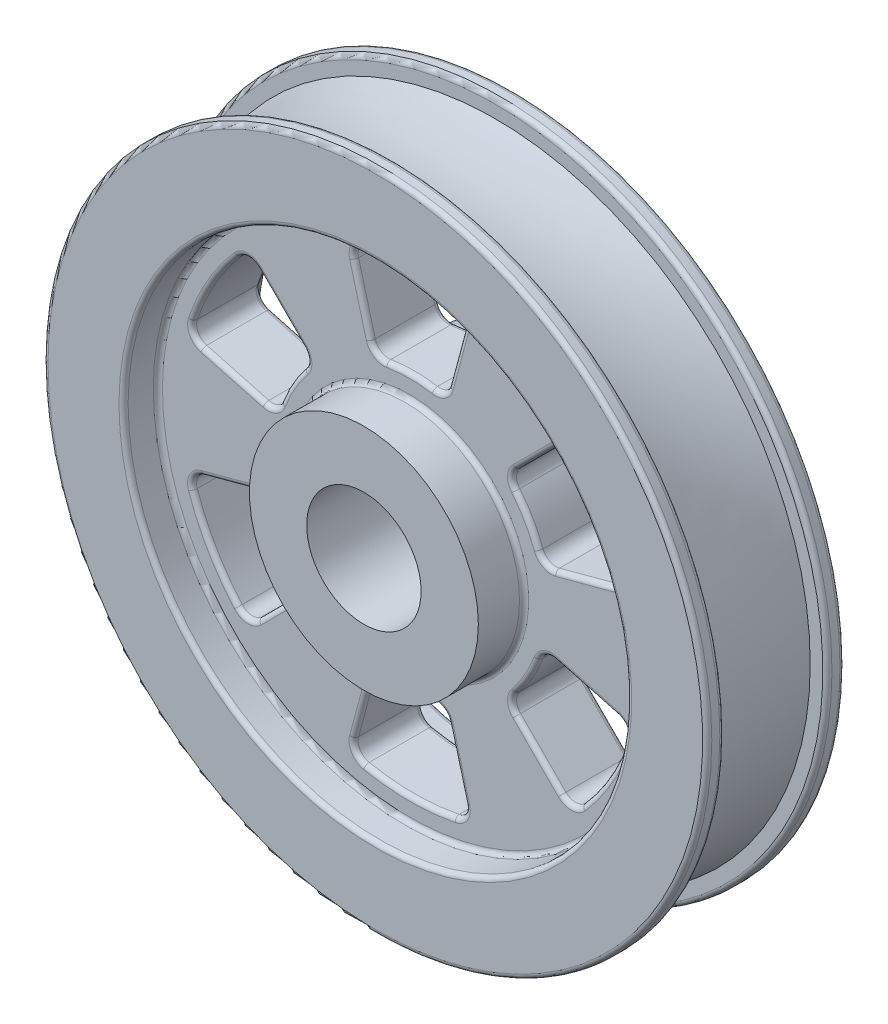
from build123d import *

# Parameters (mm, degrees)
SPOKE_HOLE_DEPTH             = 64.5
SPOKE_HOLE_PATTERN_COUNT     = 6
F_0_10_INCH_FILLETS_ROUNDS_R = 2.54


with BuildPart() as part:
    # Wheel Cross-section → Revolve1 (revolve)
    with BuildSketch(Plane(origin=(0, 0, 0), x_dir=(0, 0, -1), z_dir=(1, 0, 0))):
        with BuildLine():
            Line((44.45, 31.75), (44.45, 63.5))
            Line((44.45, 63.5), (19.05, 63.5))
            Line((19.05, 63.5), (19.05, 139.7))
            Line((19.05, 139.7), (38.1, 139.7))
            Line((38.1, 139.7), (38.1, 184.15))
            Line((38.1, 184.15), (28.575, 184.15))
            Line((28.575, 184.15), (28.575, 174.625))
            ThreePointArc((28.575, 174.625), (0, 171.922125473), (-28.575, 174.625))
            Line((-28.575, 174.625), (-28.575, 184.15))
            Line((-28.575, 184.15), (-38.1, 184.15))
            Line((-38.1, 184.15), (-38.1, 139.7))
            Line((-38.1, 139.7), (-19.05, 139.7))
            Line((-19.05, 139.7), (-19.05, 63.5))
            Line((-19.05, 63.5), (-44.45, 63.5))
            Line((-44.45, 63.5), (-44.45, 31.75))
            Line((-44.45, 31.75), (44.45, 31.75))
        make_face()
    revolve(axis=Axis((0, 0, 130.774722222), (0, 0, -1)))

    # Spoke cut-out → Spoke hole (cut, through all)
    with BuildSketch(Plane.XY.offset(19.05)):
        with BuildLine():
            Line((30.834810774, 115.077080449), (21.604380868, 80.628647064))
            ThreePointArc((21.604380868, 80.628647064), (18.350350621, 76.181930935), (12.94911461, 75.09168017))
            ThreePointArc((12.94911461, 75.09168017), (0, 76.2), (-12.94911461, 75.09168017))
            ThreePointArc((-12.94911461, 75.09168017), (-18.350350621, 76.181930935), (-21.604380868, 80.628647064))
            Line((-21.604380868, 80.628647064), (-30.834810774, 115.077080449))
            ThreePointArc((-30.834810774, 115.077080449), (-29.948546686, 121.068056198), (-24.972825508, 124.520512311))
            ThreePointArc((-24.972825508, 124.520512311), (0, 127), (24.972825508, 124.520512311))
            ThreePointArc((24.972825508, 124.520512311), (29.948546686, 121.068056198), (30.834810774, 115.077080449))
        make_face()
    spoke_hole = extrude(amount=-SPOKE_HOLE_DEPTH, mode=Mode.SUBTRACT)

    # Spoke hole pattern: Spoke hole ×6 about axis
    spoke_hole_pattern_axis = Axis((0, 0, 0), (0, 0, 1))
    for i in range(1, SPOKE_HOLE_PATTERN_COUNT):
        add(spoke_hole.rotate(spoke_hole_pattern_axis, i * 360 / SPOKE_HOLE_PATTERN_COUNT), mode=Mode.SUBTRACT)

    # 0.10 inch Fillets & Rounds
    f_0_10_inch_fillets_rounds_edges = [part.edges().sort_by_distance(p)[0] for p in [
        (-65.991135768, -38.1, -19.05),
        (-75.15066281, -22.199095661, -19.05),
        (-97.852863756, -26.219595821, -19.05),
        (-119.822285597, -34.597825862, -19.05),
        (0, -63.5, -19.05),
        (0, -139.7, -19.05),
        (-119.822285597, -34.597825862, 19.05),
        (-109.985226281, -63.5, 19.05),
        (-89.873738911, -86.470230336, 19.05),
        (-71.633267936, -71.633267936, 19.05),
        (-56.800312189, -53.982835274, 19.05),
        (-65.991135768, -38.1, 19.05),
        (-75.15066281, -22.199095661, 19.05),
        (-97.852863756, -26.219595821, 19.05),
        (0, -139.7, -38.1),
        (0, -184.15, -38.1),
        (0, -184.15, -28.575),
        (0, -127, -19.05),
        (29.948546686, -121.068056198, -19.05),
        (26.219595821, -97.852863756, -19.05),
        (18.350350621, -76.181930935, -19.05),
        (0, -76.2, -19.05),
        (-18.350350621, -76.181930935, -19.05),
        (-26.219595821, -97.852863756, -19.05),
        (-29.948546686, -121.068056198, -19.05),
        (0, -184.15, 28.575),
        (-29.948546686, -121.068056198, 19.05),
        (0, -127, 19.05),
        (29.948546686, -121.068056198, 19.05),
        (26.219595821, -97.852863756, 19.05),
        (18.350350621, -76.181930935, 19.05),
        (0, -76.2, 19.05),
        (-18.350350621, -76.181930935, 19.05),
        (-26.219595821, -97.852863756, 19.05),
        (0, -184.15, 38.1),
        (0, -139.7, 38.1),
        (0, -139.7, 19.05),
        (0, -63.5, 19.05),
        (109.985226281, -63.5, -19.05),
        (119.822285597, -34.597825862, -19.05),
        (97.852863756, -26.219595821, -19.05),
        (75.15066281, -22.199095661, -19.05),
        (65.991135768, -38.1, -19.05),
        (56.800312189, -53.982835274, -19.05),
        (71.633267936, -71.633267936, -19.05),
        (89.873738911, -86.470230336, -19.05),
        (89.873738911, -86.470230336, 19.05),
        (109.985226281, -63.5, 19.05),
        (119.822285597, -34.597825862, 19.05),
        (97.852863756, -26.219595821, 19.05),
        (75.15066281, -22.199095661, 19.05),
        (65.991135768, -38.1, 19.05),
        (56.800312189, -53.982835274, 19.05),
        (71.633267936, -71.633267936, 19.05),
        (109.985226281, 63.5, -19.05),
        (89.873738911, 86.470230336, -19.05),
        (71.633267936, 71.633267936, -19.05),
        (56.800312189, 53.982835274, -19.05),
        (65.991135768, 38.1, -19.05),
        (75.15066281, 22.199095661, -19.05),
        (97.852863756, 26.219595821, -19.05),
        (119.822285597, 34.597825862, -19.05),
        (119.822285597, 34.597825862, 19.05),
        (109.985226281, 63.5, 19.05),
        (89.873738911, 86.470230336, 19.05),
        (71.633267936, 71.633267936, 19.05),
        (56.800312189, 53.982835274, 19.05),
        (65.991135768, 38.1, 19.05),
        (75.15066281, 22.199095661, 19.05),
        (97.852863756, 26.219595821, 19.05),
        (0, 127, -19.05),
        (-29.948546686, 121.068056198, -19.05),
        (-26.219595821, 97.852863756, -19.05),
        (-18.350350621, 76.181930935, -19.05),
        (0, 76.2, -19.05),
        (18.350350621, 76.181930935, -19.05),
        (26.219595821, 97.852863756, -19.05),
        (29.948546686, 121.068056198, -19.05),
        (29.948546686, 121.068056198, 19.05),
        (0, 127, 19.05),
        (-29.948546686, 121.068056198, 19.05),
        (-26.219595821, 97.852863756, 19.05),
        (-18.350350621, 76.181930935, 19.05),
        (0, 76.2, 19.05),
        (18.350350621, 76.181930935, 19.05),
        (26.219595821, 97.852863756, 19.05),
        (-109.985226281, 63.5, -19.05),
        (-119.822285597, 34.597825862, -19.05),
        (-97.852863756, 26.219595821, -19.05),
        (-75.15066281, 22.199095661, -19.05),
        (-65.991135768, 38.1, -19.05),
        (-56.800312189, 53.982835274, -19.05),
        (-71.633267936, 71.633267936, -19.05),
        (-89.873738911, 86.470230336, -19.05),
        (-89.873738911, 86.470230336, 19.05),
        (-109.985226281, 63.5, 19.05),
        (-119.822285597, 34.597825862, 19.05),
        (-97.852863756, 26.219595821, 19.05),
        (-75.15066281, 22.199095661, 19.05),
        (-65.991135768, 38.1, 19.05),
        (-56.800312189, 53.982835274, 19.05),
        (-71.633267936, 71.633267936, 19.05),
        (-109.985226281, -63.5, -19.05),
        (-89.873738911, -86.470230336, -19.05),
        (-71.633267936, -71.633267936, -19.05),
        (-56.800312189, -53.982835274, -19.05),
    ]]
    fillet(f_0_10_inch_fillets_rounds_edges, radius=F_0_10_INCH_FILLETS_ROUNDS_R)


solid = part.part
